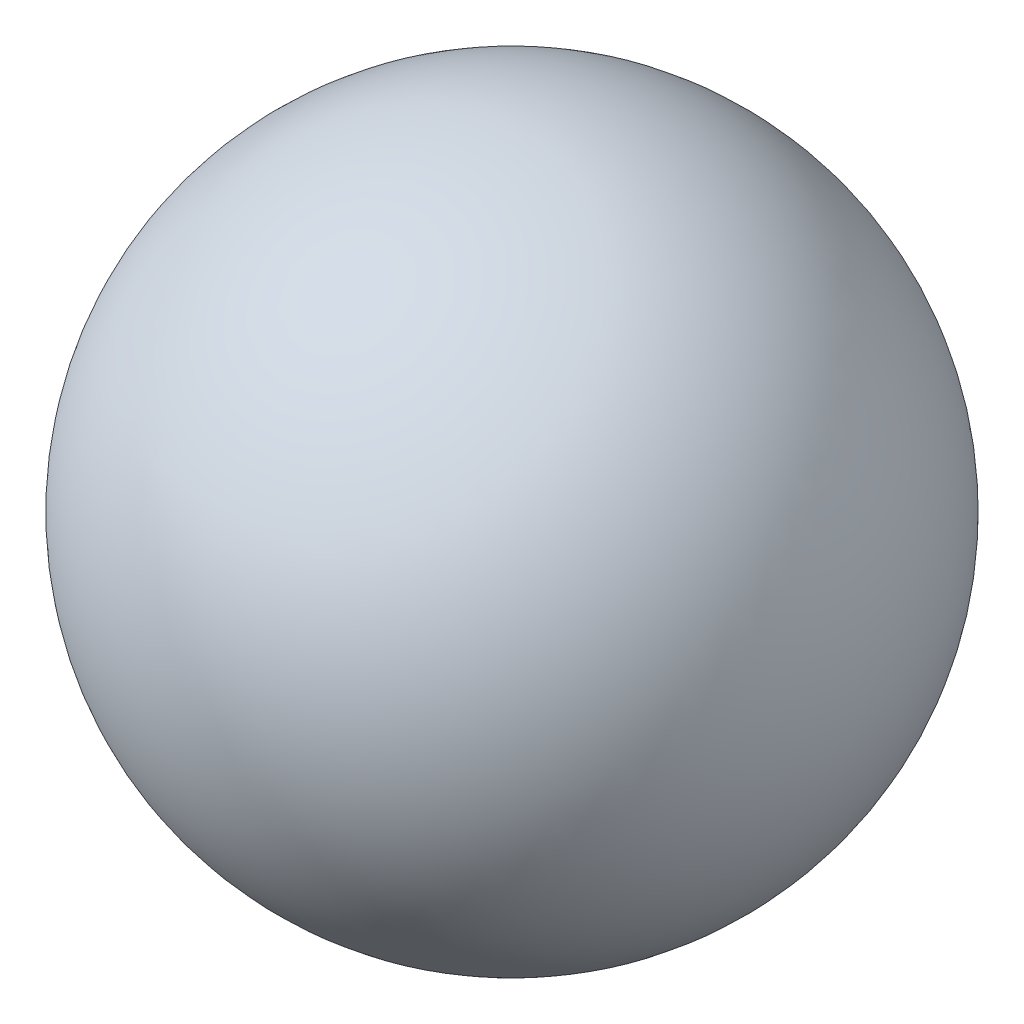
from build123d import *


with BuildPart() as part:
    # Sketch1 → Revolve1 (revolve)
    with BuildSketch(Plane.XY):
        with BuildLine():
            Line((0, -0.5), (0, 0.5))
            ThreePointArc((0, 0.5), (-0.5, 0), (0, -0.5))
        make_face()
    revolve(axis=Axis((0, -0.5, 0), (0, 1, 0)))


solid = part.part
